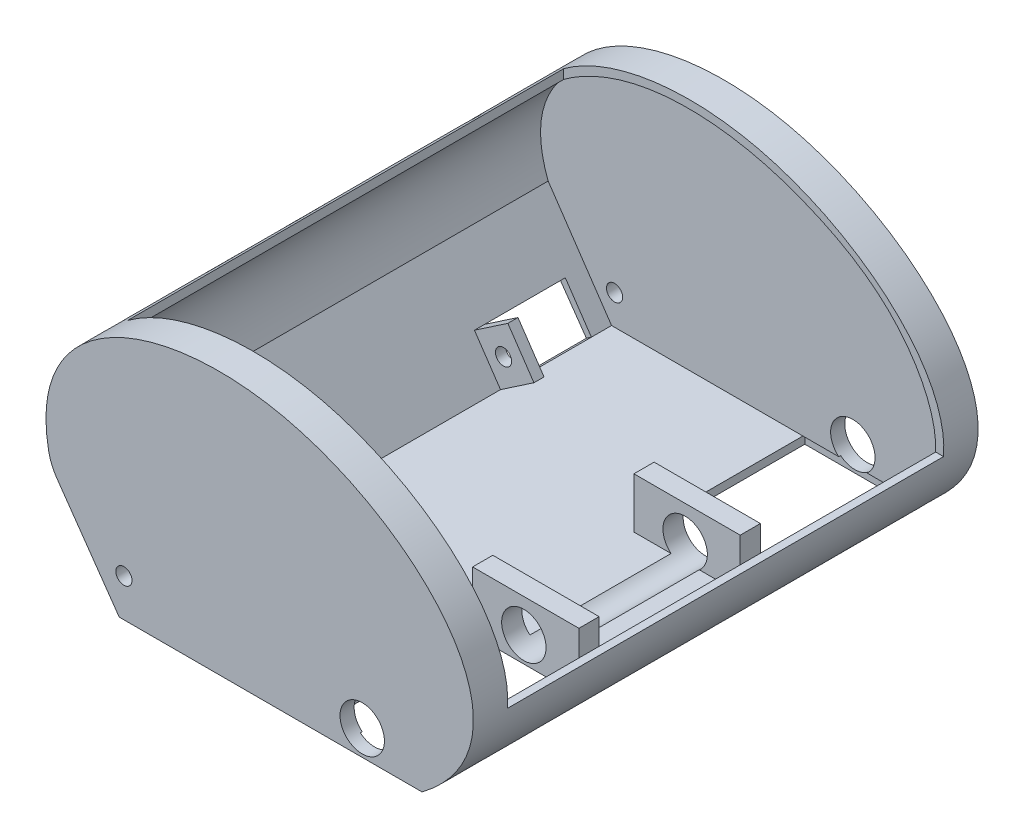
from build123d import *

# Parameters (mm, degrees)
BOSS_EXTRUDE1_DEPTH      = 250
CUT_EXTRUDE1_START       = -7
CUT_EXTRUDE1_DEPTH       = 236
CUT_EXTRUDE2_START       = 40
SKETCH3_W                = 188.244995532
SKETCH3_H                = 216
CUT_EXTRUDE2_DEPTH       = 236
FILLET1_R                = 25
SKETCH16_W               = 40
SKETCH16_H               = 23
CUT_EXTRUDE11_DEPTH      = 170
SKETCH17_W               = 5
SKETCH17_H               = 23.791120356
SKETCH17_H_2             = 23
BOSS_EXTRUDE5_DEPTH      = 20
SKETCH18_R               = 4
CUT_EXTRUDE12_DEPTH      = 58.0000001
CUT_EXTRUDE12_DEPTH_BACK = 194.0000001
SKETCH21_W               = 52
SKETCH21_H               = 74
CUT_EXTRUDE13_DEPTH      = 10
SKETCH22_W               = 52.638555516
SKETCH22_H               = 10
BOSS_EXTRUDE6_DEPTH      = 25
SKETCH24_R               = 11
CUT_EXTRUDE14_DEPTH      = 81.055617737
CUT_EXTRUDE14_DEPTH_BACK = 170.944382463


with BuildPart() as part:
    # Sketch1 → Boss-Extrude1 (new body)
    with BuildSketch(Plane.XY):
        with BuildLine():
            Line((-74.466852712, 0), (75.533147288, 0))
            add(Edge.make_bspline(
                [(75.533147288, 0), (138.063372934, 47.200510513), (16.470001542, 172.007803308), (-124.949591118, 111.301552399), (-108.081203548, 48.03596108)],
                knots=[0, 0, 0, 0, 0.526874503, 1, 1, 1, 1], degree=3))
            Line((-108.081203548, 48.03596108), (-74.466852712, 0))
        make_face()
    extrude(amount=BOSS_EXTRUDE1_DEPTH)

    # Sketch2 → Cut-Extrude1 (cut)
    with BuildSketch(Plane.XY.offset(250).offset(CUT_EXTRUDE1_START)):
        with BuildLine():
            Line((-105.002588912, 50.278247003), (-73.603513663, 4))
            Line((-73.603513663, 4), (73.163375947, 4))
            Line((73.163375947, 4), (80.793344513, 10.72835486))
            add(Edge.make_bspline(
                [(80.793344513, 10.72835486), (92.651817418, 19.563808902), (103.009839439, 45.205558115), (79.954027593, 88.91810325), (40.607899873, 112.95610518), (-11.204752472, 129.142722192), (-79.431682825, 124.667635826), (-117.344714605, 82.323825457), (-105.002588912, 50.278247003)],
                knots=[0.016278873, 0.016278873, 0.016278873, 0.016278873, 0.12675304, 0.268313114, 0.414746674, 0.542882576, 0.761532881, 1, 1, 1, 1], degree=3))
        make_face()
    extrude(amount=-CUT_EXTRUDE1_DEPTH, mode=Mode.SUBTRACT)

    # Sketch3 → Cut-Extrude2 (cut)
    with BuildSketch(Plane(origin=(0, 0, 0), x_dir=(1, 0, 0), z_dir=(0, 1, 0)).offset(CUT_EXTRUDE2_START)):
        with Locations((6.82953452, -125)):
            Rectangle(SKETCH3_W, SKETCH3_H)
    extrude(amount=CUT_EXTRUDE2_DEPTH, mode=Mode.SUBTRACT)

    # Fillet1
    fillet1_edges = [part.edges().sort_by_distance(p)[0] for p in [
        (-108.081203548, 48.03596108, 125),
    ]]
    fillet(fillet1_edges, radius=FILLET1_R)

    # Sketch16 → Cut-Extrude11 (cut)
    with BuildSketch(Plane(origin=(-48.543156815, -32.935781547, 0), x_dir=(0, 0, -1), z_dir=(0.827509179, 0.561452187, 0))):
        with Locations((-212.328725108, 56.926010788)):
            Rectangle(SKETCH16_W, SKETCH16_H)
        with Locations((-37, 56.134890432)):
            Rectangle(SKETCH16_W, SKETCH16_H)
    extrude(amount=-CUT_EXTRUDE11_DEPTH, mode=Mode.SUBTRACT)

    # Sketch17 → Boss-Extrude5 (add)
    with BuildSketch(Plane(origin=(-48.543156815, -32.935781547, 0), x_dir=(0, 0, -1), z_dir=(0.827509179, 0.561452187, 0))):
        with Locations((-189.828725108, 56.53045061)):
            Rectangle(SKETCH17_W, SKETCH17_H)
        with Locations((-59.5, 56.134890432)):
            Rectangle(SKETCH17_W, SKETCH17_H_2)
    extrude(amount=BOSS_EXTRUDE5_DEPTH)

    # Sketch18 → Cut-Extrude12 (cut, two sides)
    with BuildSketch(Plane(origin=(0, 0, 57), x_dir=(-1, 0, 0), z_dir=(0, 0, -1))) as cut_extrude12_sk:
        with Locations((72.12467311, 18.843671615)):
            Circle(SKETCH18_R)
    extrude(amount=CUT_EXTRUDE12_DEPTH, mode=Mode.SUBTRACT)
    extrude(cut_extrude12_sk.sketch, amount=-CUT_EXTRUDE12_DEPTH_BACK, mode=Mode.SUBTRACT)

    # Sketch21 → Cut-Extrude13 (cut)
    with BuildSketch(Plane(origin=(0, 4, 0), x_dir=(1, 0, 0), z_dir=(0, 1, 0))):
        with Locations((47.163375947, -206.944382363)):
            Rectangle(SKETCH21_W, SKETCH21_H)
    cut_extrude13 = extrude(amount=-CUT_EXTRUDE13_DEPTH, mode=Mode.SUBTRACT)

    # Sketch22 → Boss-Extrude6 (add)
    with BuildSketch(Plane(origin=(0, 4, 0), x_dir=(1, 0, 0), z_dir=(0, 1, 0))):
        with Locations((46.844098189, -164.944382363)):
            Rectangle(SKETCH22_W, SKETCH22_H)
    boss_extrude6 = extrude(amount=BOSS_EXTRUDE6_DEPTH)

    # Mirror2: Cut-Extrude13, Boss-Extrude6 across plane
    add(cut_extrude13.mirror(Plane.XY.offset(125)), mode=Mode.SUBTRACT)
    add(boss_extrude6.mirror(Plane.XY.offset(125)))

    # Sketch24 → Cut-Extrude14 (cut, two sides)
    with BuildSketch(Plane.XY.offset(169.944382363)) as cut_extrude14_sk:
        with Locations((45.890595185, 12.5)):
            Circle(SKETCH24_R)
    extrude(amount=CUT_EXTRUDE14_DEPTH, mode=Mode.SUBTRACT)
    extrude(cut_extrude14_sk.sketch, amount=-CUT_EXTRUDE14_DEPTH_BACK, mode=Mode.SUBTRACT)


solid = part.part
